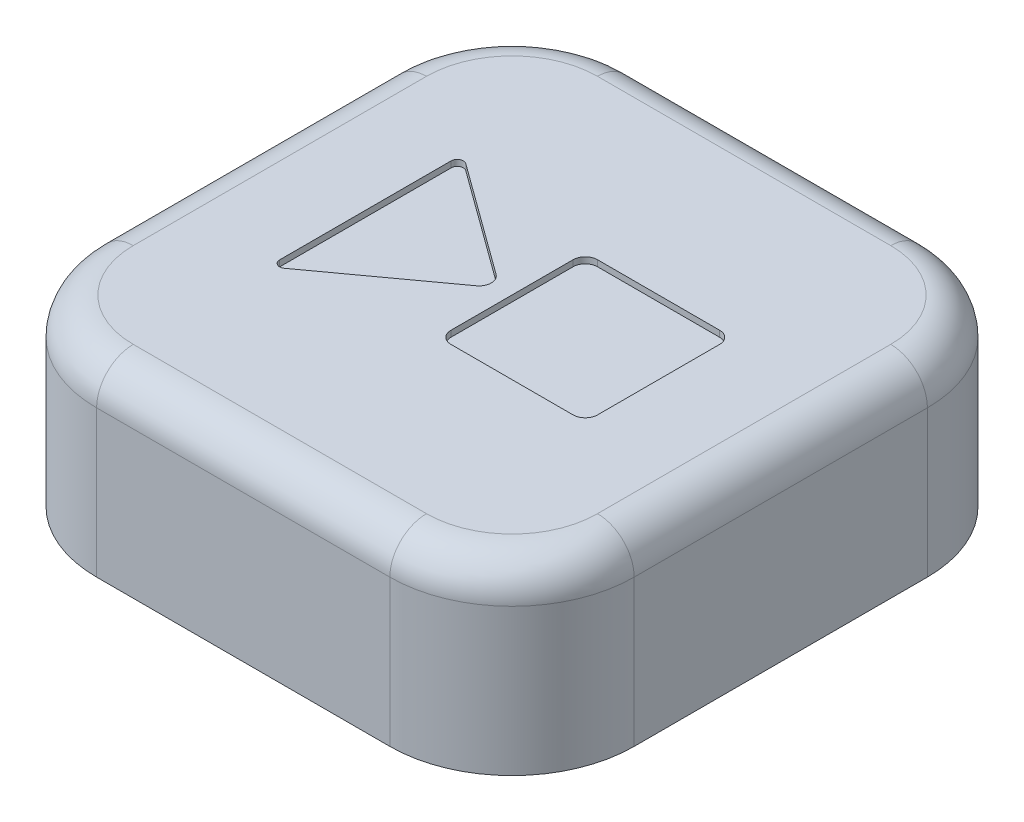
from build123d import *

# Parameters (mm, degrees)
BOSS_EXTRU_1_DEPTH      = 15
CONG_1_R                = 3
ENL_V_MAT_EXTRU_1_DEPTH = 0.5


with BuildPart() as part:
    # Esquisse1 → Boss.-Extru.1 (new body)
    with BuildSketch(Plane(origin=(0, 0, 0), x_dir=(1, 0, 0), z_dir=(0, 1, 0))):
        with BuildLine():
            Line((-12, -22), (12, -22))
            ThreePointArc((12, -22), (19.071067812, -19.071067812), (22, -12))
            Line((22, -12), (22, 12))
            ThreePointArc((22, 12), (19.071067812, 19.071067812), (12, 22))
            Line((12, 22), (-12, 22))
            ThreePointArc((-12, 22), (-19.071067812, 19.071067812), (-22, 12))
            Line((-22, 12), (-22, -12))
            ThreePointArc((-22, -12), (-19.071067812, -19.071067812), (-12, -22))
        make_face()
    extrude(amount=BOSS_EXTRU_1_DEPTH)

    # Congé1
    cong_1_edges = [part.edges().sort_by_distance(p)[0] for p in [
        (19.071067812, 15, 19.071067812),
        (22, 15, 0),
        (19.071067812, 15, -19.071067812),
        (0, 15, -22),
        (-19.071067812, 15, -19.071067812),
        (-22, 15, 0),
        (-19.071067812, 15, 19.071067812),
        (0, 15, 22),
    ]]
    fillet(cong_1_edges, radius=CONG_1_R)

    # Esquisse2 → Enlèv. mat.-Extru.1 (cut)
    with BuildSketch(Plane(origin=(0, 15, 0), x_dir=(1, 0, 0), z_dir=(0, 1, 0))):
        with BuildLine():
            Line((-12, 7.018114977), (-12, -7.018114977))
            ThreePointArc((-12, -7.018114977), (-11.726888823, -7.46367245), (-11.205914151, -7.422483019))
            Line((-11.205914151, -7.422483019), (-2.112012116, -0.808736084))
            ThreePointArc((-2.112012116, -0.808736084), (-1.700183814, 0), (-2.112012116, 0.808736084))
            Line((-2.112012116, 0.808736084), (-11.205914151, 7.422483019))
            ThreePointArc((-11.205914151, 7.422483019), (-11.726888823, 7.46367245), (-12, 7.018114977))
        make_face()
        with BuildLine():
            Line((1, 6), (11, 6))
            ThreePointArc((11, 6), (11.707106781, 5.707106781), (12, 5))
            Line((12, 5), (12, -5))
            ThreePointArc((12, -5), (11.707106781, -5.707106781), (11, -6))
            Line((11, -6), (1, -6))
            ThreePointArc((1, -6), (0.292893219, -5.707106781), (0, -5))
            Line((0, -5), (0, 5))
            ThreePointArc((0, 5), (0.292893219, 5.707106781), (1, 6))
        make_face()
    extrude(amount=-ENL_V_MAT_EXTRU_1_DEPTH, mode=Mode.SUBTRACT)


solid = part.part
